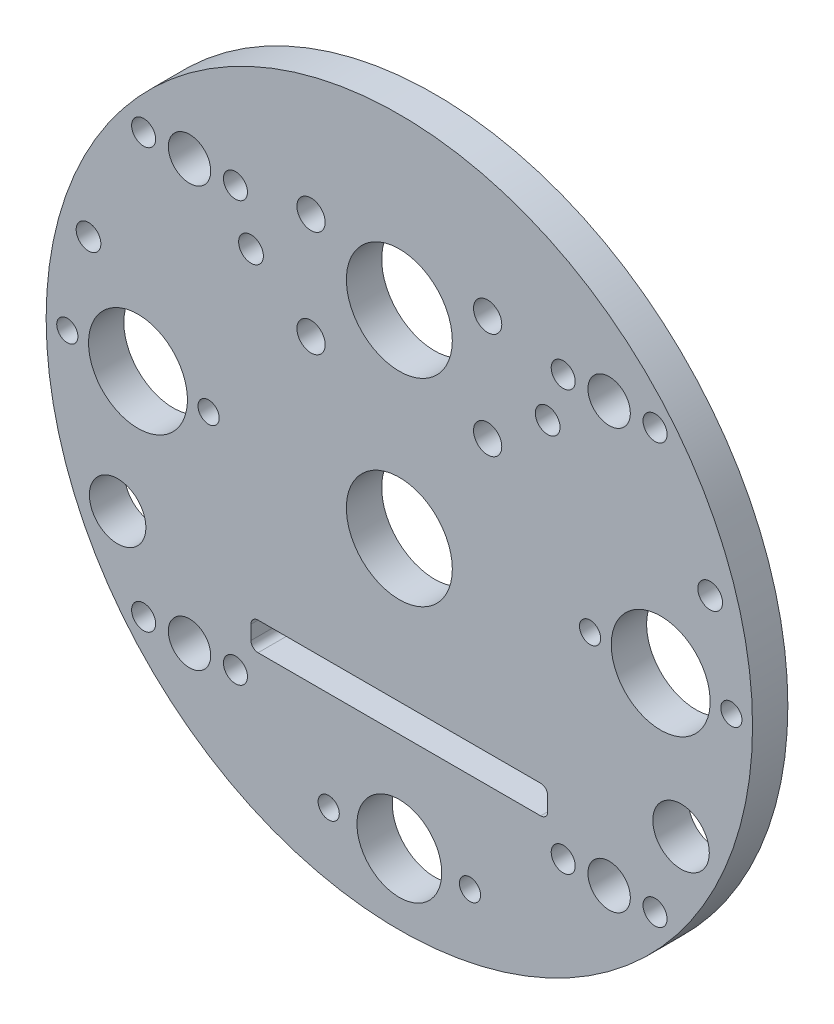
from build123d import *

# Parameters (mm, degrees)
SKETCH1_R                  = 50
BOSS_EXTRUDE1_DEPTH        = 5
F_14_0_14_DIAMETER_HOLE1_D = 14
SKETCH9_R                  = 7.5
CUT_EXTRUDE1_DEPTH         = 10
SKETCH10_R                 = 2
CUT_EXTRUDE2_DEPTH         = 10
SKETCH11_R                 = 7.5
CUT_EXTRUDE3_DEPTH         = 10
SKETCH12_R                 = 3
CUT_EXTRUDE4_DEPTH         = 10
CIRPATTERN1_COUNT          = 4
SKETCH13_R                 = 1.5
SKETCH13_R_2               = 6
CUT_EXTRUDE5_DEPTH         = 10
SKETCH14_R                 = 1.75
CUT_EXTRUDE6_DEPTH         = 10
SKETCH15_R                 = 4
CUT_EXTRUDE7_DEPTH         = 10
CUT_EXTRUDE8_DEPTH         = 10
M3_CLEARANCE_HOLE1_D       = 3.4
MIRROR3_COPY_1_D           = 3.4


with BuildPart() as part:
    # Sketch1 → Boss-Extrude1 (new body)
    with BuildSketch(Plane.XY):
        Circle(SKETCH1_R)
    extrude(amount=BOSS_EXTRUDE1_DEPTH)

    # Ø14.0 (14) Diameter Hole1 (through all)
    with Locations(Plane(origin=(0, 0, 0), x_dir=(-1, 0, 0), z_dir=(0, 0, -1))):
        with Locations((37, 0), (-37, 0)):
            Hole(F_14_0_14_DIAMETER_HOLE1_D / 2)

    # Sketch9 → Cut-Extrude1 (cut)
    with BuildSketch(Plane.XY.offset(5)):
        with Locations((0, 26)):
            Circle(SKETCH9_R)
    extrude(amount=-CUT_EXTRUDE1_DEPTH, mode=Mode.SUBTRACT)

    # Sketch10 → Cut-Extrude2 (cut)
    with BuildSketch(Plane.XY.offset(5)):
        with Locations((-12.5, 31.5)):
            Circle(SKETCH10_R)
        with Locations((-12.5, 16.5)):
            Circle(SKETCH10_R)
        with Locations((12.5, 31.5)):
            Circle(SKETCH10_R)
        with Locations((12.5, 16.5)):
            Circle(SKETCH10_R)
    extrude(amount=-CUT_EXTRUDE2_DEPTH, mode=Mode.SUBTRACT)

    # Sketch11 → Cut-Extrude3 (cut)
    with BuildSketch(Plane.XY.offset(5)):
        with Locations((0, -2)):
            Circle(SKETCH11_R)
    extrude(amount=-CUT_EXTRUDE3_DEPTH, mode=Mode.SUBTRACT)

    # Sketch12 → Cut-Extrude4 (cut)
    with BuildSketch(Plane.XY.offset(5)):
        with Locations((-29.69848481, 29.69848481)):
            Circle(SKETCH12_R)
    cut_extrude4 = extrude(amount=-CUT_EXTRUDE4_DEPTH, mode=Mode.SUBTRACT)

    # CirPattern1: Cut-Extrude4 ×4 about axis
    cirpattern1_axis = Axis((0, 0, 0), (0, 0, 1))
    for i in range(1, CIRPATTERN1_COUNT):
        add(cut_extrude4.rotate(cirpattern1_axis, i * 360 / CIRPATTERN1_COUNT), mode=Mode.SUBTRACT)

    # Sketch13 → Cut-Extrude5 (cut)
    with BuildSketch(Plane.XY.offset(5)):
        with Locations((-47, 0)):
            Circle(SKETCH13_R)
        with Locations((-27, 0)):
            Circle(SKETCH13_R)
        with Locations((27, 0)):
            Circle(SKETCH13_R)
        with Locations((47, 0)):
            Circle(SKETCH13_R)
        with Locations((10, -40)):
            Circle(SKETCH13_R)
        with Locations((-10, -40)):
            Circle(SKETCH13_R)
        with Locations((0, -40)):
            Circle(SKETCH13_R_2)
    extrude(amount=-CUT_EXTRUDE5_DEPTH, mode=Mode.SUBTRACT)

    # Sketch14 → Cut-Extrude6 (cut)
    with BuildSketch(Plane.XY.offset(5)):
        with Locations((-21, 23)):
            Circle(SKETCH14_R)
        with Locations((-44, 13)):
            Circle(SKETCH14_R)
    cut_extrude6 = extrude(amount=-CUT_EXTRUDE6_DEPTH, mode=Mode.SUBTRACT)

    # Mirror1: Cut-Extrude6 across plane
    add(cut_extrude6.mirror(Plane(origin=(0, 0, 0), x_dir=(0, 0, 1), z_dir=(1, 0, 0))), mode=Mode.SUBTRACT)

    # Sketch15 → Cut-Extrude7 (cut)
    with BuildSketch(Plane.XY.offset(5)):
        with Locations((-39.87754263, -18.595203517)):
            Circle(SKETCH15_R)
        with Locations((39.87754263, -18.595203517)):
            Circle(SKETCH15_R)
    extrude(amount=-CUT_EXTRUDE7_DEPTH, mode=Mode.SUBTRACT)

    # Sketch16 → Cut-Extrude8 (cut)
    with BuildSketch(Plane.XY.offset(5)):
        with BuildLine():
            Line((-20, -22), (20, -22))
            ThreePointArc((20, -22), (20.707106781, -22.292893219), (21, -23))
            Line((21, -23), (21, -25))
            ThreePointArc((21, -25), (20.707106781, -25.707106781), (20, -26))
            Line((20, -26), (-20, -26))
            ThreePointArc((-20, -26), (-20.707106781, -25.707106781), (-21, -25))
            Line((-21, -25), (-21, -23))
            ThreePointArc((-21, -23), (-20.707106781, -22.292893219), (-20, -22))
        make_face()
    extrude(amount=-CUT_EXTRUDE8_DEPTH, mode=Mode.SUBTRACT)

    # M3 Clearance Hole1 (through all)
    with Locations(Plane.XY.offset(5)):
        with Locations((-36.19848481, -29.69848481), (-23.19848481, -29.69848481)):
            m3_clearance_hole1 = Hole(M3_CLEARANCE_HOLE1_D / 2)

    # Mirror2: M3 Clearance Hole1 across plane
    add(m3_clearance_hole1.mirror(Plane.ZX), mode=Mode.SUBTRACT)

    # Mirror3: M3 Clearance Hole1 across plane
    add(m3_clearance_hole1.mirror(Plane(origin=(0, 0, 0), x_dir=(0, 0, 1), z_dir=(1, 0, 0))), mode=Mode.SUBTRACT)

    # Mirror3 copy 1 (through all)
    with Locations(Plane(origin=(0, 0, 5), x_dir=(-1, 0, 0), z_dir=(0, 0, 1))):
        with Locations((-36.19848481, -29.69848481), (-23.19848481, -29.69848481)):
            Hole(MIRROR3_COPY_1_D / 2)


solid = part.part
